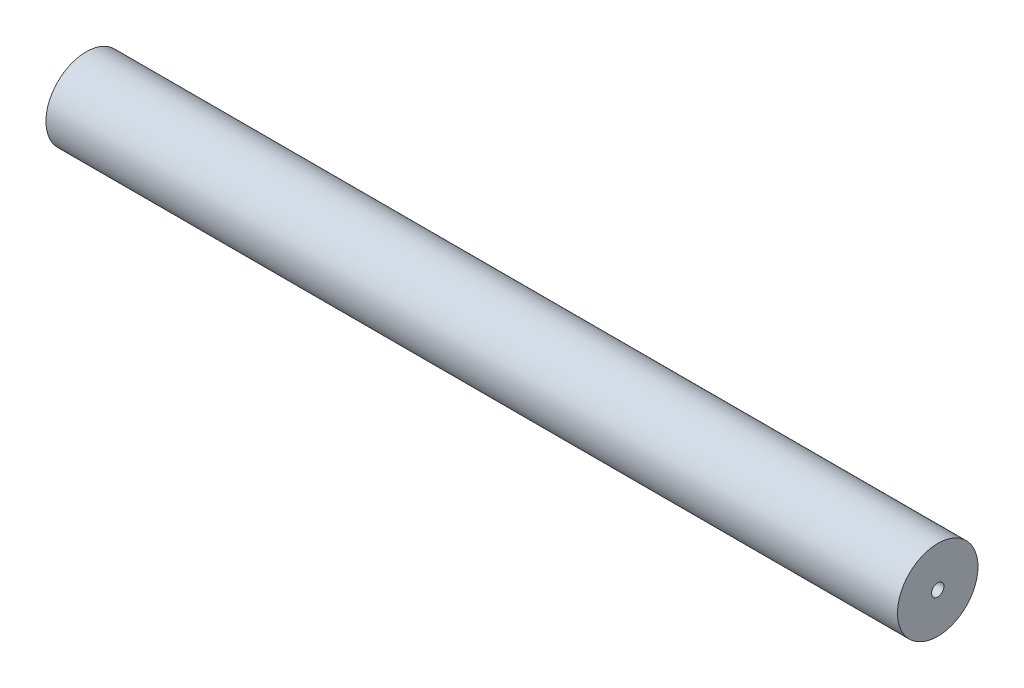
from build123d import *


with BuildPart() as part:
    # Sketch1 → Revolve1 (revolve)
    with BuildSketch(Plane.XY):
        Polygon((11, 0.5), (11, 3.25), (-57.75, 3.25), (-57.75, 2.25), (10, 2.25), (10, 0.5), align=None)
    revolve(axis=Axis((13.5, 0, 0), (-1, 0, 0)))


solid = part.part
